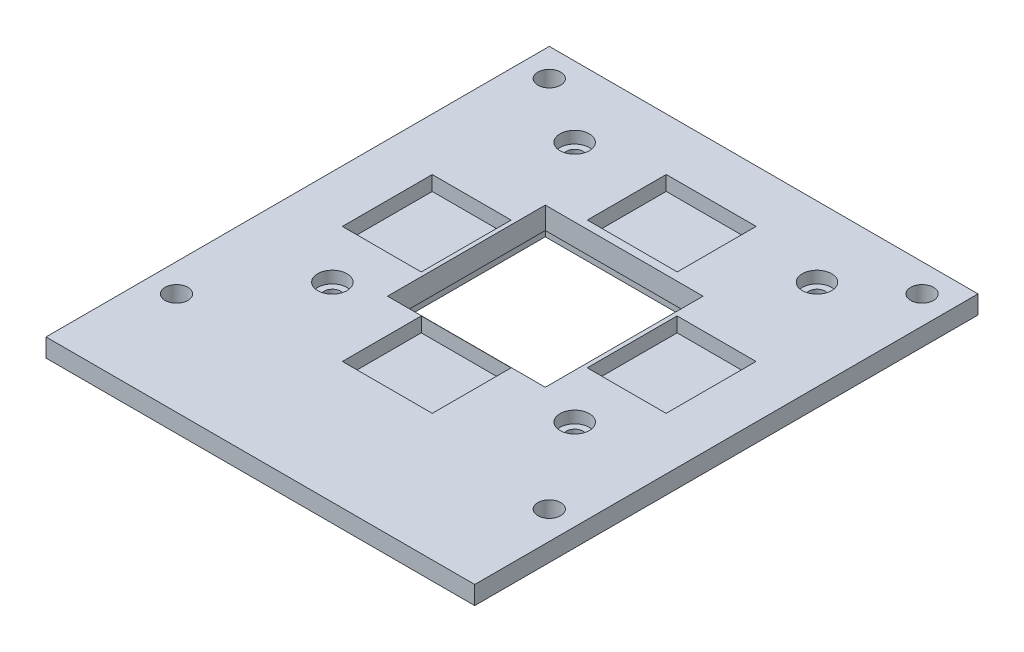
from build123d import *

# Parameters (mm, degrees)
SKETCH1_W                   = 116.84
SKETCH1_H                   = 137.16
SKETCH1_R                   = 3.110430672
BOSS_EXTRUDE1_DEPTH         = 5
SKETCH12_W                  = 85
SKETCH12_H                  = 23.975046692
BOSS_EXTRUDE15_DEPTH        = 5
SKETCH17_W                  = 50
SKETCH17_H                  = 50
BOSS_EXTRUDE18_DEPTH        = 6
SKETCH10_W                  = 43
SKETCH10_H                  = 43
BOSS_EXTRUDE19_DEPTH        = 25
SKETCH19_W                  = 55
SKETCH19_H                  = 55
BOSS_EXTRUDE20_DEPTH        = 11
SKETCH20_R                  = 2.25
BOSS_EXTRUDE22_DEPTH        = 25
BOSS_EXTRUDE22_2_DEPTH      = 25
BOSS_EXTRUDE22_3_DEPTH      = 25
BOSS_EXTRUDE22_4_DEPTH      = 25
SKETCH21_W                  = 24.5
SKETCH21_H                  = 21.5
BOSS_EXTRUDE23_DEPTH        = 4
SKETCH21_W_2                = 21.5
SKETCH21_H_2                = 24.5
BOSS_EXTRUDE23_2_DEPTH      = 4
BOSS_EXTRUDE23_3_DEPTH      = 4
BOSS_EXTRUDE23_4_DEPTH      = 4
SKETCH25_R                  = 4
BOSS_EXTRUDE24_DEPTH        = 10
BOSS_EXTRUDE24_DEPTH_BACK   = 3.25
BOSS_EXTRUDE24_2_DEPTH      = 10
BOSS_EXTRUDE24_2_DEPTH_BACK = 3.25
BOSS_EXTRUDE24_3_DEPTH      = 10
BOSS_EXTRUDE24_3_DEPTH_BACK = 3.25
BOSS_EXTRUDE24_4_DEPTH      = 10
BOSS_EXTRUDE24_4_DEPTH_BACK = 3.25


with BuildPart() as part:
    # Sketch1 → Boss-Extrude1 (new body)
    with BuildSketch(Plane(origin=(0, 0, 0), x_dir=(1, 0, 0), z_dir=(0, 1, 0))):
        with Locations((-0.693486938, -16.384561015)):
            Rectangle(SKETCH1_W, SKETCH1_H)
        with Locations((-51.493486938, 44.575438985)):
            Circle(SKETCH1_R, mode=Mode.SUBTRACT)
        with Locations((50.106513062, -57.024561015)):
            Circle(SKETCH1_R, mode=Mode.SUBTRACT)
        with Locations((-51.493486938, -57.024561015)):
            Circle(SKETCH1_R, mode=Mode.SUBTRACT)
        with Locations((50.106513062, 44.575438985)):
            Circle(SKETCH1_R, mode=Mode.SUBTRACT)
    extrude(amount=-BOSS_EXTRUDE1_DEPTH)


with BuildPart() as body_2:
    # Sketch12 → Boss-Extrude15 (new body)
    with BuildSketch(Plane(origin=(0, 0, 0), x_dir=(1, 0, 0), z_dir=(0, 1, 0))):
        with Locations((0, 58)):
            Rectangle(SKETCH12_W, SKETCH12_H)
    extrude(amount=BOSS_EXTRUDE15_DEPTH)


with BuildPart() as body_3:
    # Sketch17 → Boss-Extrude18 (new body)
    with BuildSketch(Plane(origin=(0, 0, 0), x_dir=(1, 0, 0), z_dir=(0, 1, 0))):
        with Locations((-0.7, -7.31)):
            Rectangle(SKETCH17_W, SKETCH17_H)
    extrude(amount=-BOSS_EXTRUDE18_DEPTH)


with BuildPart() as body_4:
    # Sketch10 → Boss-Extrude19 (new body, symmetric)
    with BuildSketch(Plane(origin=(0, 0, 0), x_dir=(1, 0, 0), z_dir=(0, 1, 0))):
        with Locations((-0.695517903, -7.307291257)):
            Rectangle(SKETCH10_W, SKETCH10_H)
    extrude(amount=BOSS_EXTRUDE19_DEPTH, both=True)


with BuildPart() as body_5:
    # Sketch19 → Boss-Extrude20 (new body)
    with BuildSketch(Plane(origin=(0, 0, 0), x_dir=(1, 0, 0), z_dir=(0, 1, 0))):
        with Locations((-0.7, -7.31)):
            Rectangle(SKETCH19_W, SKETCH19_H)
    extrude(amount=-BOSS_EXTRUDE20_DEPTH)


with BuildPart() as part_1:
    add(part.part)

    # Combine1: cut body 2
    add(body_2.part, mode=Mode.SUBTRACT)


with BuildPart() as body_3_1:
    # Body-Move/Copy4: moved
    add(body_3.part.moved(Location((0, -6, 0))))


with BuildPart() as body_5_1:
    add(body_5.part)

    # Combine4: cut body 3
    add(body_3_1.part, mode=Mode.SUBTRACT)

    # Combine7: union part
    add(part_1.part)

    # Combine8: cut body 4
    add(body_4.part, mode=Mode.SUBTRACT)


with BuildPart() as body_2_2:
    # Sketch20 → Boss-Extrude22 (new body, symmetric)
    with BuildSketch(Plane(origin=(0, 0, 0), x_dir=(1, 0, 0), z_dir=(0, 1, 0))):
        with Locations((33.02, 33.02)):
            Circle(SKETCH20_R)
    extrude(amount=BOSS_EXTRUDE22_DEPTH, both=True)


with BuildPart() as body_3_2:
    # Sketch20 → Boss-Extrude22 2 (new body, symmetric)
    with BuildSketch(Plane(origin=(0, 0, 0), x_dir=(1, 0, 0), z_dir=(0, 1, 0))):
        with Locations((33.02, -33.02)):
            Circle(SKETCH20_R)
    extrude(amount=BOSS_EXTRUDE22_2_DEPTH, both=True)


with BuildPart() as body_4_2:
    # Sketch20 → Boss-Extrude22 3 (new body, symmetric)
    with BuildSketch(Plane(origin=(0, 0, 0), x_dir=(1, 0, 0), z_dir=(0, 1, 0))):
        with Locations((-33.02, -33.02)):
            Circle(SKETCH20_R)
    extrude(amount=BOSS_EXTRUDE22_3_DEPTH, both=True)


with BuildPart() as body_5_2:
    # Sketch20 → Boss-Extrude22 4 (new body, symmetric)
    with BuildSketch(Plane(origin=(0, 0, 0), x_dir=(1, 0, 0), z_dir=(0, 1, 0))):
        with Locations((-33.02, 33.02)):
            Circle(SKETCH20_R)
    extrude(amount=BOSS_EXTRUDE22_4_DEPTH, both=True)


with BuildPart() as body_5_3:
    add(body_5_1.part)

    # Combine9: cut body 4 2, body 3 2, body 2 2, body 5 2
    add(body_4_2.part, mode=Mode.SUBTRACT)
    add(body_3_2.part, mode=Mode.SUBTRACT)
    add(body_2_2.part, mode=Mode.SUBTRACT)
    add(body_5_2.part, mode=Mode.SUBTRACT)


with BuildPart() as body_2_3:
    # Sketch21 → Boss-Extrude23 (new body)
    with BuildSketch(Plane(origin=(0, 0, 0), x_dir=(1, 0, 0), z_dir=(0, 1, 0))):
        with Locations((-0.69, 27.145438985)):
            Rectangle(SKETCH21_W, SKETCH21_H)
    extrude(amount=-BOSS_EXTRUDE23_DEPTH)


with BuildPart() as body_3_3:
    # Sketch21 → Boss-Extrude23 2 (new body)
    with BuildSketch(Plane(origin=(0, 0, 0), x_dir=(1, 0, 0), z_dir=(0, 1, 0))):
        with Locations((32.676513062, -6.25)):
            Rectangle(SKETCH21_W_2, SKETCH21_H_2)
    extrude(amount=-BOSS_EXTRUDE23_2_DEPTH)


with BuildPart() as body_4_3:
    # Sketch21 → Boss-Extrude23 3 (new body)
    with BuildSketch(Plane(origin=(0, 0, 0), x_dir=(1, 0, 0), z_dir=(0, 1, 0))):
        with Locations((-34.063486938, -6.25)):
            Rectangle(SKETCH21_W_2, SKETCH21_H_2)
    extrude(amount=-BOSS_EXTRUDE23_3_DEPTH)


with BuildPart() as body_5_3_1:
    # Sketch21 → Boss-Extrude23 4 (new body)
    with BuildSketch(Plane(origin=(0, 0, 0), x_dir=(1, 0, 0), z_dir=(0, 1, 0))):
        with Locations((-0.69, -39.614561015)):
            Rectangle(SKETCH21_W, SKETCH21_H)
    extrude(amount=-BOSS_EXTRUDE23_4_DEPTH)


with BuildPart() as body_5_4:
    add(body_5_3.part)

    # Combine10: cut body 3 3, body 2 3, body 5 3, body 4 3
    add(body_3_3.part, mode=Mode.SUBTRACT)
    add(body_2_3.part, mode=Mode.SUBTRACT)
    add(body_5_3_1.part, mode=Mode.SUBTRACT)
    add(body_4_3.part, mode=Mode.SUBTRACT)


with BuildPart() as body_2_4:
    # Sketch25 → Boss-Extrude24 (new body, two sides)
    with BuildSketch(Plane(origin=(0, 0, 0), x_dir=(1, 0, 0), z_dir=(0, 1, 0))) as boss_extrude24_sk:
        with Locations((33.02, 33.02)):
            Circle(SKETCH25_R)
    extrude(amount=BOSS_EXTRUDE24_DEPTH)
    extrude(boss_extrude24_sk.sketch, amount=-BOSS_EXTRUDE24_DEPTH_BACK)


with BuildPart() as body_3_4:
    # Sketch25 → Boss-Extrude24 2 (new body, two sides)
    with BuildSketch(Plane(origin=(0, 0, 0), x_dir=(1, 0, 0), z_dir=(0, 1, 0))) as boss_extrude24_2_sk:
        with Locations((-33.02, 33.02)):
            Circle(SKETCH25_R)
    extrude(amount=BOSS_EXTRUDE24_2_DEPTH)
    extrude(boss_extrude24_2_sk.sketch, amount=-BOSS_EXTRUDE24_2_DEPTH_BACK)


with BuildPart() as body_4_4:
    # Sketch25 → Boss-Extrude24 3 (new body, two sides)
    with BuildSketch(Plane(origin=(0, 0, 0), x_dir=(1, 0, 0), z_dir=(0, 1, 0))) as boss_extrude24_3_sk:
        with Locations((-33.02, -33.02)):
            Circle(SKETCH25_R)
    extrude(amount=BOSS_EXTRUDE24_3_DEPTH)
    extrude(boss_extrude24_3_sk.sketch, amount=-BOSS_EXTRUDE24_3_DEPTH_BACK)


with BuildPart() as body_5_4_1:
    # Sketch25 → Boss-Extrude24 4 (new body, two sides)
    with BuildSketch(Plane(origin=(0, 0, 0), x_dir=(1, 0, 0), z_dir=(0, 1, 0))) as boss_extrude24_4_sk:
        with Locations((33.02, -33.02)):
            Circle(SKETCH25_R)
    extrude(amount=BOSS_EXTRUDE24_4_DEPTH)
    extrude(boss_extrude24_4_sk.sketch, amount=-BOSS_EXTRUDE24_4_DEPTH_BACK)


with BuildPart() as body_5_5:
    add(body_5_4.part)

    # Combine11: cut body 4 4, body 3 4, body 2 4, body 5 4
    add(body_4_4.part, mode=Mode.SUBTRACT)
    add(body_3_4.part, mode=Mode.SUBTRACT)
    add(body_2_4.part, mode=Mode.SUBTRACT)
    add(body_5_4_1.part, mode=Mode.SUBTRACT)


solid = body_5_5.part
